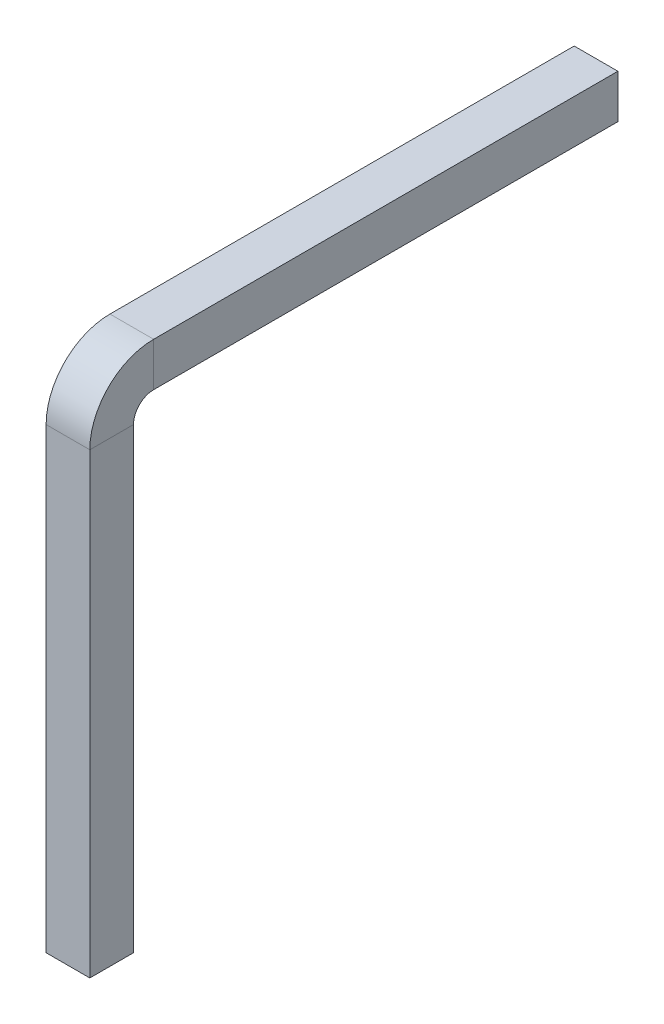
from build123d import *

# Parameters (mm, degrees)
SKETCH1_W     = 0.64
SKETCH1_H     = 0.64
CHAMFER1_SIZE = 0.2


with BuildPart() as part:
    # Sweep1: sweep along a path in Sketch2
    with BuildLine(Plane(origin=(0, 0, 0), x_dir=(0, 0, -1), z_dir=(1, 0, 0))) as sweep1_path:
        Line((0.014667815, 0), (0.014667815, 6.9))
        ThreePointArc((0.014667815, 6.9), (0.190403746, 7.324264069), (0.614667815, 7.5))
        Line((0.614667815, 7.5), (7.614667815, 7.5))
    # Sketch1 → Sweep1 (sweep)
    with BuildSketch(Plane(origin=(0, 0, 0), x_dir=(1, 0, 0), z_dir=(0, 1, 0))):
        Rectangle(SKETCH1_W, SKETCH1_H)
    sweep(path=sweep1_path.line)

    # Chamfer1
    chamfer1_edges = [part.edges().sort_by_distance(p)[0] for p in [
        (0, 0, 0.32),
        (0.32, 0, 0),
        (0, 0, -0.32),
        (-0.32, 7.514667815, -7.614667815),
        (0, 7.834667815, -7.614667815),
        (0.32, 7.514667815, -7.614667815),
        (0, 7.194667815, -7.614667815),
        (-0.32, 0, 0),
    ]]
    chamfer(chamfer1_edges, length=CHAMFER1_SIZE)


solid = part.part
